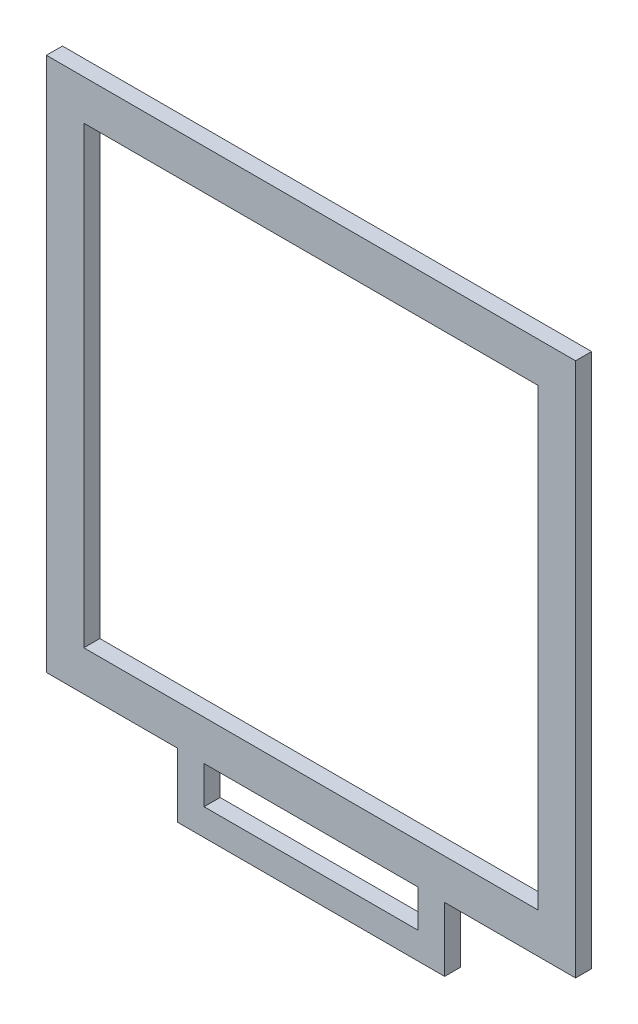
from build123d import *

# Parameters (mm, degrees)
CROQUIS1_W              = 99
CROQUIS1_H              = 100
CROQUIS1_W_2            = 85
CROQUIS1_H_2            = 85
SALIENTE_EXTRUIR1_DEPTH = 3
SALIENTE_EXTRUIR2_DEPTH = 3


with BuildPart() as part:
    # Croquis1 → Saliente-Extruir1 (new body)
    with BuildSketch(Plane.XY):
        with Locations((49.5, 50)):
            Rectangle(CROQUIS1_W, CROQUIS1_H)
        with Locations((49.5, 50)):
            Rectangle(CROQUIS1_W_2, CROQUIS1_H_2, mode=Mode.SUBTRACT)
    extrude(amount=SALIENTE_EXTRUIR1_DEPTH)

    # Croquis2 → Saliente-Extruir2 (add)
    with BuildSketch(Plane.XY.offset(3)):
        Polygon((24.5, 0), (29.5, 0), (29.5, -7), (69.5, -7), (69.5, 0), (74.5, 0), (74.5, -12), (24.5, -12), align=None)
    extrude(amount=-SALIENTE_EXTRUIR2_DEPTH)


solid = part.part
